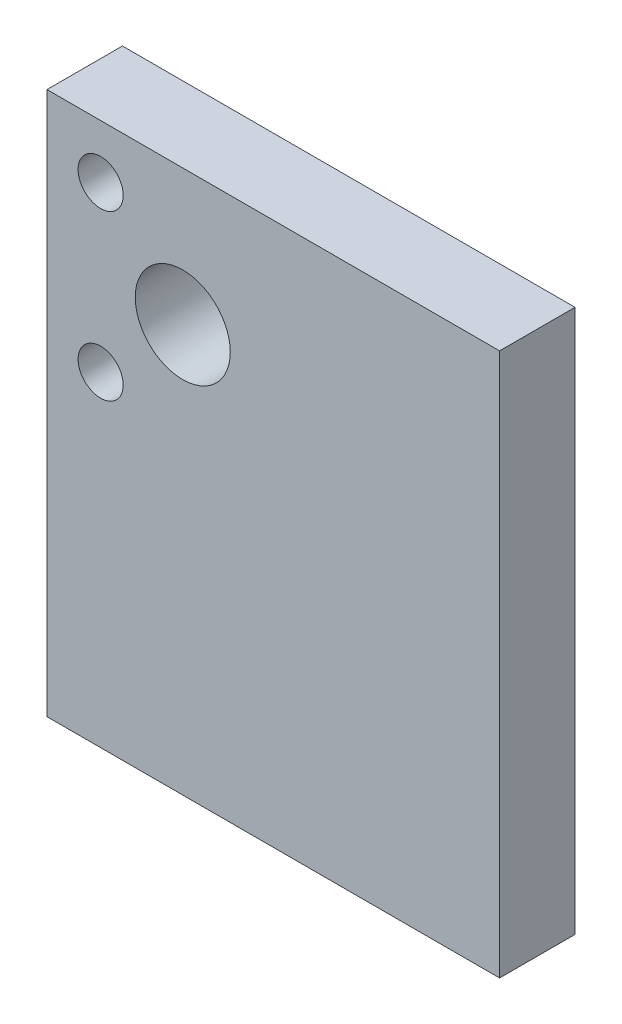
from build123d import *

# Parameters (mm, degrees)
SKETCH1_W                 = 38.1
SKETCH1_H                 = 45.72
BOSS_EXTRUDE1_DEPTH       = 6.35
SKETCH2_R                 = 4
CUT_EXTRUDE1_DEPTH        = 1
CUT_EXTRUDE1_DEPTH_BACK   = 7.35
F_6_CLEARANCE_HOLE2_D     = 3.7973
F_6_CLEARANCE_HOLE2_DEPTH = 6.35


with BuildPart() as part:
    # Sketch1 → Boss-Extrude1 (new body)
    with BuildSketch(Plane.XY):
        with Locations((19.05, 22.86)):
            Rectangle(SKETCH1_W, SKETCH1_H)
    extrude(amount=BOSS_EXTRUDE1_DEPTH)

    # Sketch2 → Cut-Extrude1 (cut, two sides)
    with BuildSketch(Plane.XY.offset(6.35)) as cut_extrude1_sk:
        with Locations((11.43, 34.29)):
            Circle(SKETCH2_R)
    extrude(amount=CUT_EXTRUDE1_DEPTH, mode=Mode.SUBTRACT)
    extrude(cut_extrude1_sk.sketch, amount=-CUT_EXTRUDE1_DEPTH_BACK, mode=Mode.SUBTRACT)

    # #6 Clearance Hole2
    with Locations(Plane.XY.offset(6.35)):
        with Locations((4.515202787, 41.204797213), (4.515202787, 27.375202787)):
            Hole(F_6_CLEARANCE_HOLE2_D / 2, depth=F_6_CLEARANCE_HOLE2_DEPTH)


solid = part.part
